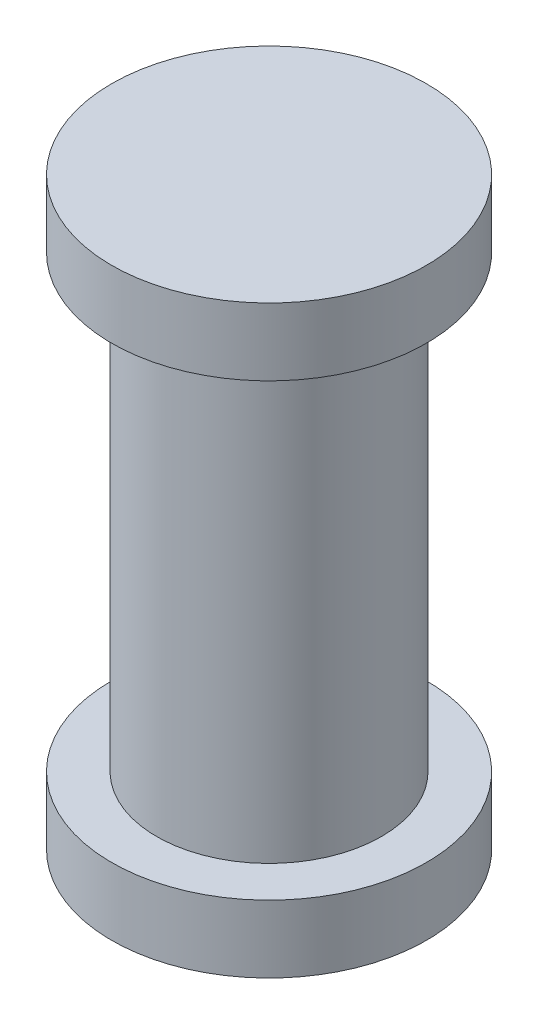
from build123d import *


with BuildPart() as part:
    # Sketch1 → Revolve1 (revolve)
    with BuildSketch(Plane.XY):
        Polygon((0, 0), (7, 0), (7, 3), (5, 3), (5, 23), (7, 23), (7, 26), (0, 26), align=None)
    revolve(axis=Axis((0, 26, 0), (0, -1, 0)))


solid = part.part
